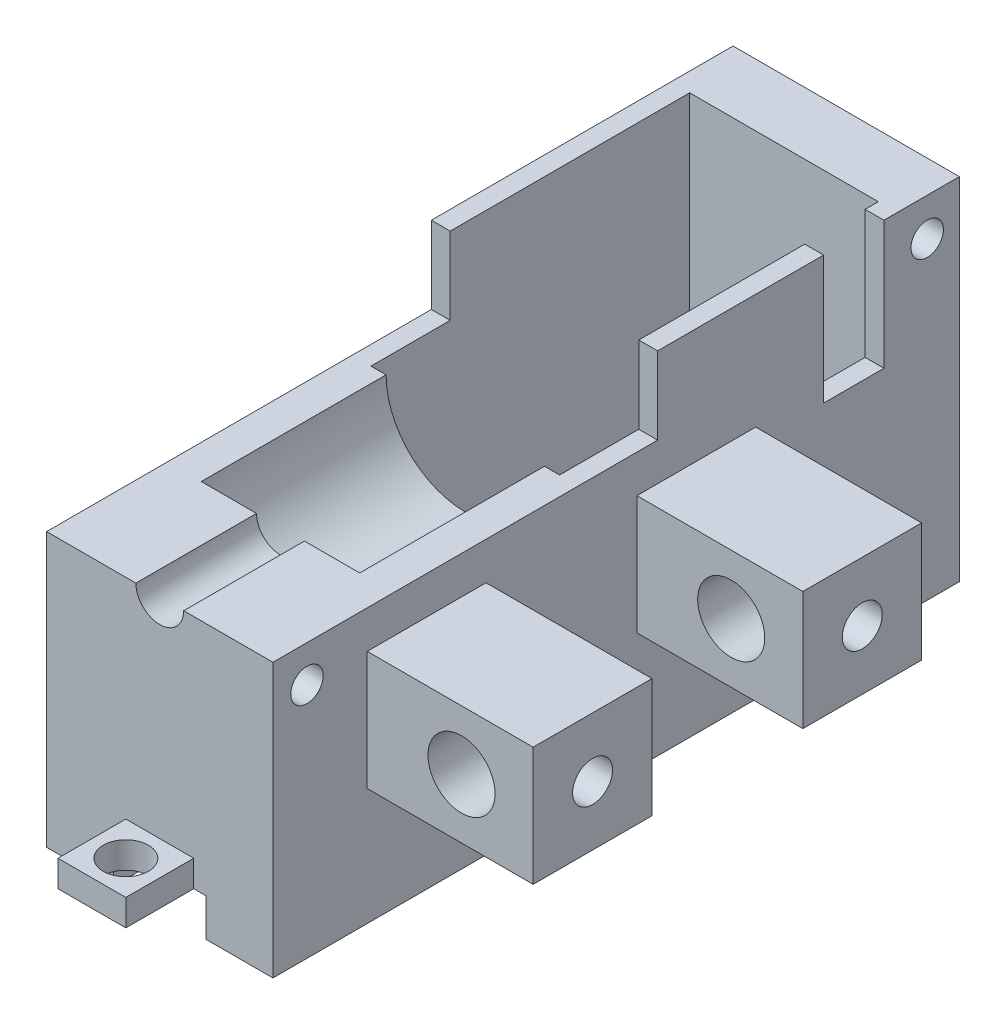
from build123d import *

# Parameters (mm, degrees)
SKETCH1_W                = 30
SKETCH1_H                = 41.5
BOSS_EXTRUDE1_DEPTH      = 40
SKETCH2_W                = 25
SKETCH2_H                = 29
CUT_EXTRUDE1_DEPTH       = 35.5
SKETCH3_W                = 25
SKETCH3_H                = 35.5
CUT_EXTRUDE2_DEPTH       = 19
SKETCH7_W                = 9
SKETCH7_H                = 9
BOSS_EXTRUDE2_DEPTH      = 3.5
SKETCH8_R                = 3
CUT_EXTRUDE3_DEPTH       = 7
BOSS_EXTRUDE3_DEPTH      = 35
SKETCH10_W               = 30
SKETCH10_H               = 31.25
BOSS_EXTRUDE4_DEPTH      = 16
CUT_EXTRUDE4_DEPTH       = 25
SKETCH12_W               = 8
SKETCH12_H               = 17
CUT_EXTRUDE5_DEPTH       = 2.5
SKETCH13_R               = 2.15
CUT_EXTRUDE6_DEPTH       = 10
SKETCH17_W               = 15.75
SKETCH17_H               = 15.75
BOSS_EXTRUDE5_DEPTH      = 22
SKETCH18_R               = 4.445
CUT_EXTRUDE7_DEPTH       = 62.75
SKETCH19_R               = 2.15
CUT_EXTRUDE8_DEPTH       = 5
SKETCH21_R               = 2.15
CUT_EXTRUDE9_DEPTH       = 5
SKETCH23_W               = 8.875
SKETCH23_H               = 91
BOSS_EXTRUDE6_DEPTH      = 5
CUT_EXTRUDE10_REACH      = 122.109
CUT_EXTRUDE10_END_RADIUS = 4.445
SKETCH25_R               = 2.15
CUT_EXTRUDE11_DEPTH      = 119.170427817
SKETCH26_W               = 25
SKETCH26_H               = 2.5
CUT_EXTRUDE12_DEPTH      = 25.25
SKETCH27_W               = 25
SKETCH27_H               = 8
CUT_EXTRUDE13_DEPTH      = 25.25


with BuildPart() as part:
    # Sketch1 → Boss-Extrude1 (new body)
    with BuildSketch(Plane.XY):
        with Locations((15, 20.75)):
            Rectangle(SKETCH1_W, SKETCH1_H)
    extrude(amount=BOSS_EXTRUDE1_DEPTH)

    # Sketch2 → Cut-Extrude1 (cut)
    with BuildSketch(Plane(origin=(0, 41.5, 0), x_dir=(1, 0, 0), z_dir=(0, 1, 0))):
        with Locations((15, -22.75)):
            Rectangle(SKETCH2_W, SKETCH2_H)
    extrude(amount=-CUT_EXTRUDE1_DEPTH, mode=Mode.SUBTRACT)

    # Sketch3 → Cut-Extrude2 (cut)
    with BuildSketch(Plane(origin=(0, 0, 37.25), x_dir=(-1, 0, 0), z_dir=(0, 0, -1))):
        with Locations((-15, 23.75)):
            Rectangle(SKETCH3_W, SKETCH3_H)
    extrude(amount=-CUT_EXTRUDE2_DEPTH, mode=Mode.SUBTRACT)

    # Sketch7 → Boss-Extrude2 (add)
    with BuildSketch(Plane.XZ):
        with Locations((15, -4.5)):
            Rectangle(SKETCH7_W, SKETCH7_H)
    boss_extrude2 = extrude(amount=-BOSS_EXTRUDE2_DEPTH)

    # Sketch8 → Cut-Extrude3 (cut)
    with BuildSketch(Plane(origin=(0, 3.5, 0), x_dir=(1, 0, 0), z_dir=(0, 1, 0))):
        with Locations(Location((15, 4.5, 0), (0, 0, 270))):
            Circle(SKETCH8_R)
    cut_extrude3 = extrude(amount=-CUT_EXTRUDE3_DEPTH, mode=Mode.SUBTRACT)

    # Sketch9 → Boss-Extrude3 (add)
    with BuildSketch(Plane.XY.offset(40)):
        with BuildLine():
            Line((0, 0), (0, 31.25))
            Line((0, 31.25), (4.5, 31.25))
            ThreePointArc((4.5, 31.25), (15, 20.75), (25.5, 31.25))
            Line((25.5, 31.25), (30, 31.25))
            Line((30, 31.25), (30, 0))
            Line((30, 0), (0, 0))
        make_face()
    extrude(amount=BOSS_EXTRUDE3_DEPTH)

    # Sketch10 → Boss-Extrude4 (add)
    with BuildSketch(Plane.XY.offset(75)):
        with Locations((15, 15.625)):
            Rectangle(SKETCH10_W, SKETCH10_H)
    extrude(amount=BOSS_EXTRUDE4_DEPTH)

    # Mirror1: Boss-Extrude2, Cut-Extrude3 across plane
    add(boss_extrude2.mirror(Plane.XY.offset(45.5)))
    add(cut_extrude3.mirror(Plane.XY.offset(45.5)), mode=Mode.SUBTRACT)

    # Sketch11 → Cut-Extrude4 (cut)
    with BuildSketch(Plane.XY.offset(91)):
        with BuildLine():
            Line((11.825, 31.25), (18.175, 31.25))
            ThreePointArc((18.175, 31.25), (15, 28.075), (11.825, 31.25))
        make_face()
    extrude(amount=-CUT_EXTRUDE4_DEPTH, mode=Mode.SUBTRACT)

    # Sketch12 → Cut-Extrude5 (cut)
    with BuildSketch(Plane.ZY.offset(-30)):
        with Locations((14, 33)):
            Rectangle(SKETCH12_W, SKETCH12_H)
    extrude(amount=CUT_EXTRUDE5_DEPTH, mode=Mode.SUBTRACT)

    # Sketch13 → Cut-Extrude6 (cut)
    with BuildSketch(Plane.ZY):
        with Locations((4.265954999, 36.5)):
            Circle(SKETCH13_R)
    cut_extrude6 = extrude(amount=-CUT_EXTRUDE6_DEPTH, mode=Mode.SUBTRACT)

    # Mirror2: Cut-Extrude6 across plane
    add(cut_extrude6.mirror(Plane(origin=(15, 0, 0), x_dir=(0, 0, 1), z_dir=(1, 0, 0))), mode=Mode.SUBTRACT)

    # Sketch17 → Boss-Extrude5 (add)
    with BuildSketch(Plane(origin=(30, 0, 0), x_dir=(0, 0, -1), z_dir=(1, 0, 0))):
        with Locations((-70.625, 18.375)):
            Rectangle(SKETCH17_W, SKETCH17_H)
        with Locations((-34.875, 18.375)):
            Rectangle(SKETCH17_W, SKETCH17_H)
    extrude(amount=BOSS_EXTRUDE5_DEPTH)

    # Sketch18 → Cut-Extrude7 (cut)
    with BuildSketch(Plane.XY.offset(78.5)):
        with Locations(Location((42.5, 18.375, 0), (0, 0, 270))):
            Circle(SKETCH18_R)
    extrude(amount=-CUT_EXTRUDE7_DEPTH, mode=Mode.SUBTRACT)

    # Sketch19 → Cut-Extrude8 (cut)
    with BuildSketch(Plane(origin=(30, 0, 0), x_dir=(0, 0, -1), z_dir=(1, 0, 0))):
        with Locations((-86.486504599, 26.395706225)):
            Circle(SKETCH19_R)
    extrude(amount=-CUT_EXTRUDE8_DEPTH, mode=Mode.SUBTRACT)

    # Sketch21 → Cut-Extrude9 (cut)
    with BuildSketch(Plane.ZY):
        with Locations(Location((86.486504599, 26.395706225, 0), (0, 0, 180))):
            Circle(SKETCH21_R)
    extrude(amount=-CUT_EXTRUDE9_DEPTH, mode=Mode.SUBTRACT)

    # Sketch23 → Boss-Extrude6 (add)
    with BuildSketch(Plane(origin=(0, 0, 0), x_dir=(-1, 0, 0), z_dir=(0, -1, 0))):
        with Locations((-25.5625, -45.5)):
            Rectangle(SKETCH23_W, SKETCH23_H)
        with Locations((-4.4375, -45.5)):
            Rectangle(SKETCH23_W, SKETCH23_H)
    extrude(amount=BOSS_EXTRUDE6_DEPTH)

    # Cut-Extrude10: up to this cylinder (the profile starts outside it)
    cut_extrude10_end = Plane(origin=(42.5, 18.375, 52.75), z_dir=(0, 0, 1)) * Cylinder(CUT_EXTRUDE10_END_RADIUS, 289.858, mode=Mode.PRIVATE)
    # Sketch24 → Cut-Extrude10 (cut, up to the surface)
    with BuildSketch(Plane(origin=(52, 0, 0), x_dir=(0, 0, -1), z_dir=(1, 0, 0)), mode=Mode.PRIVATE) as cut_extrude10_sk1:
        with BuildLine():
            ThreePointArc((-67.975, 18.375), (-70.625, 21.025), (-73.275, 18.375))
            Line((-73.275, 18.375), (-67.975, 18.375))
        make_face()
    cut_extrude10_tool1 = extrude(cut_extrude10_sk1.sketch, amount=-CUT_EXTRUDE10_REACH, mode=Mode.PRIVATE) - cut_extrude10_end
    add(cut_extrude10_tool1.solids().sort_by_distance((52, 19.499695, 70.625))[0], mode=Mode.SUBTRACT)
    # Sketch24 → Cut-Extrude10 (cut, up to the surface)
    with BuildSketch(Plane(origin=(52, 0, 0), x_dir=(0, 0, -1), z_dir=(1, 0, 0)), mode=Mode.PRIVATE) as cut_extrude10_sk2:
        with BuildLine():
            Line((-67.975, 18.375), (-73.275, 18.375))
            ThreePointArc((-73.275, 18.375), (-70.625, 15.725), (-67.975, 18.375))
        make_face()
    cut_extrude10_tool2 = extrude(cut_extrude10_sk2.sketch, amount=-CUT_EXTRUDE10_REACH, mode=Mode.PRIVATE) - cut_extrude10_end
    add(cut_extrude10_tool2.solids().sort_by_distance((52, 17.250305, 70.625))[0], mode=Mode.SUBTRACT)
    # Sketch24 → Cut-Extrude10 (cut, up to the surface)
    with BuildSketch(Plane(origin=(52, 0, 0), x_dir=(0, 0, -1), z_dir=(1, 0, 0)), mode=Mode.PRIVATE) as cut_extrude10_sk3:
        with BuildLine():
            ThreePointArc((-32.225, 18.375), (-34.875, 21.025), (-37.525, 18.375))
            Line((-37.525, 18.375), (-32.225, 18.375))
        make_face()
    cut_extrude10_tool3 = extrude(cut_extrude10_sk3.sketch, amount=-CUT_EXTRUDE10_REACH, mode=Mode.PRIVATE) - cut_extrude10_end
    add(cut_extrude10_tool3.solids().sort_by_distance((52, 19.499695, 34.875))[0], mode=Mode.SUBTRACT)
    # Sketch24 → Cut-Extrude10 (cut, up to the surface)
    with BuildSketch(Plane(origin=(52, 0, 0), x_dir=(0, 0, -1), z_dir=(1, 0, 0)), mode=Mode.PRIVATE) as cut_extrude10_sk4:
        with BuildLine():
            Line((-32.225, 18.375), (-37.525, 18.375))
            ThreePointArc((-37.525, 18.375), (-34.875, 15.725), (-32.225, 18.375))
        make_face()
    cut_extrude10_tool4 = extrude(cut_extrude10_sk4.sketch, amount=-CUT_EXTRUDE10_REACH, mode=Mode.PRIVATE) - cut_extrude10_end
    add(cut_extrude10_tool4.solids().sort_by_distance((52, 17.250305, 34.875))[0], mode=Mode.SUBTRACT)
    # Sketch24 → Cut-Extrude10 (cut, up to the surface)
    with BuildSketch(Plane(origin=(52, 0, 0), x_dir=(0, 0, -1), z_dir=(1, 0, 0)), mode=Mode.PRIVATE) as cut_extrude10_sk5:
        with BuildLine():
            ThreePointArc((-32.225, 18.375), (-34.875, 21.025), (-37.525, 18.375))
            Line((-37.525, 18.375), (-32.225, 18.375))
        make_face()
    cut_extrude10_tool5 = extrude(cut_extrude10_sk5.sketch, amount=-CUT_EXTRUDE10_REACH, mode=Mode.PRIVATE) - cut_extrude10_end
    add(cut_extrude10_tool5.solids().sort_by_distance((52, 19.499695, 34.875))[0], mode=Mode.SUBTRACT)
    # Sketch24 → Cut-Extrude10 (cut, up to the surface)
    with BuildSketch(Plane(origin=(52, 0, 0), x_dir=(0, 0, -1), z_dir=(1, 0, 0)), mode=Mode.PRIVATE) as cut_extrude10_sk6:
        with BuildLine():
            Line((-32.225, 18.375), (-37.525, 18.375))
            ThreePointArc((-37.525, 18.375), (-34.875, 15.725), (-32.225, 18.375))
        make_face()
    cut_extrude10_tool6 = extrude(cut_extrude10_sk6.sketch, amount=-CUT_EXTRUDE10_REACH, mode=Mode.PRIVATE) - cut_extrude10_end
    add(cut_extrude10_tool6.solids().sort_by_distance((52, 17.250305, 34.875))[0], mode=Mode.SUBTRACT)
    # Sketch24 → Cut-Extrude10 (cut, up to the surface)
    with BuildSketch(Plane(origin=(52, 0, 0), x_dir=(0, 0, -1), z_dir=(1, 0, 0)), mode=Mode.PRIVATE) as cut_extrude10_sk7:
        with BuildLine():
            ThreePointArc((-67.975, 18.375), (-70.625, 21.025), (-73.275, 18.375))
            Line((-73.275, 18.375), (-67.975, 18.375))
        make_face()
    cut_extrude10_tool7 = extrude(cut_extrude10_sk7.sketch, amount=-CUT_EXTRUDE10_REACH, mode=Mode.PRIVATE) - cut_extrude10_end
    add(cut_extrude10_tool7.solids().sort_by_distance((52, 19.499695, 70.625))[0], mode=Mode.SUBTRACT)
    # Sketch24 → Cut-Extrude10 (cut, up to the surface)
    with BuildSketch(Plane(origin=(52, 0, 0), x_dir=(0, 0, -1), z_dir=(1, 0, 0)), mode=Mode.PRIVATE) as cut_extrude10_sk8:
        with BuildLine():
            Line((-67.975, 18.375), (-73.275, 18.375))
            ThreePointArc((-73.275, 18.375), (-70.625, 15.725), (-67.975, 18.375))
        make_face()
    cut_extrude10_tool8 = extrude(cut_extrude10_sk8.sketch, amount=-CUT_EXTRUDE10_REACH, mode=Mode.PRIVATE) - cut_extrude10_end
    add(cut_extrude10_tool8.solids().sort_by_distance((52, 17.250305, 70.625))[0], mode=Mode.SUBTRACT)

    # Sketch25 → Cut-Extrude11 (cut, through all)
    with BuildSketch(Plane(origin=(0, 6, 0), x_dir=(1, 0, 0), z_dir=(0, 1, 0))):
        with Locations(Location((15, -16, 0), (0, 0, 270))):
            Circle(SKETCH25_R)
        with Locations(Location((15, -31, 0), (0, 0, 270))):
            Circle(SKETCH25_R)
    extrude(amount=-CUT_EXTRUDE11_DEPTH, mode=Mode.SUBTRACT)

    # Sketch26 → Cut-Extrude12 (cut)
    with BuildSketch(Plane(origin=(0, 31.25, 0), x_dir=(1, 0, 0), z_dir=(0, 1, 0))):
        with Locations((15, -41.25)):
            Rectangle(SKETCH26_W, SKETCH26_H)
    extrude(amount=-CUT_EXTRUDE12_DEPTH, mode=Mode.SUBTRACT)

    # Sketch27 → Cut-Extrude13 (cut)
    with BuildSketch(Plane(origin=(0, 31.25, 0), x_dir=(1, 0, 0), z_dir=(0, 1, 0))):
        with Locations((15, -46.5)):
            Rectangle(SKETCH27_W, SKETCH27_H)
    extrude(amount=-CUT_EXTRUDE13_DEPTH, mode=Mode.SUBTRACT)


solid = part.part
